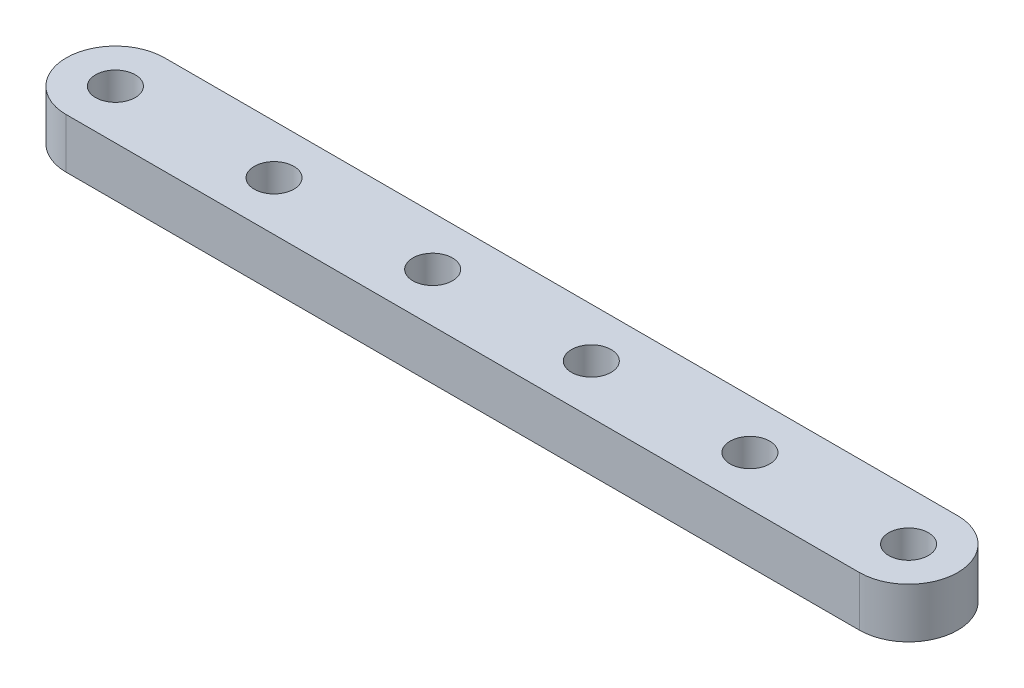
from build123d import *

# Parameters (mm, degrees)
BOSS_EXTRUDE1_DEPTH     = 2
SKETCH2_R               = 1.27
BOSS_EXTRUDE2_DEPTH     = 1.2
CUT_EXTRUDE1_DEPTH      = 35.254233315
CUT_EXTRUDE1_DEPTH_BACK = 35.254233315
SKETCH2_3_R             = 1.27
CUT_EXTRUDE2_DEPTH      = 35.254233315


with BuildPart() as part:
    # Sketch1 → Boss-Extrude1 (new body)
    with BuildSketch(Plane(origin=(0, 0, 0), x_dir=(1, 0, 0), z_dir=(0, 1, 0))):
        with BuildLine():
            Line((24.13, -8.89), (-24.13, -8.89))
            ThreePointArc((-24.13, -8.89), (-33.02, 0), (-24.13, 8.89))
            Line((-24.13, 8.89), (24.13, 8.89))
            ThreePointArc((24.13, 8.89), (33.02, 0), (24.13, -8.89))
        make_face()
    extrude(amount=BOSS_EXTRUDE1_DEPTH)

    # Sketch2 → Boss-Extrude2 (add)
    with BuildSketch(Plane(origin=(0, 2, 0), x_dir=(1, 0, 0), z_dir=(0, 1, 0))):
        with BuildLine():
            ThreePointArc((-25.4, 3.1496), (-28.5496, 0), (-25.4, -3.1496))
            Line((-25.4, -3.1496), (25.4, -3.1496))
            ThreePointArc((25.4, -3.1496), (28.5496, 0), (25.4, 3.1496))
            Line((25.4, 3.1496), (-25.4, 3.1496))
        make_face()
        with Locations((-25.4, 0)):
            Circle(SKETCH2_R, mode=Mode.SUBTRACT)
        with Locations((-15.24, 0)):
            Circle(SKETCH2_R, mode=Mode.SUBTRACT)
        with Locations((-5.08, 0)):
            Circle(SKETCH2_R, mode=Mode.SUBTRACT)
        with Locations((5.08, 0)):
            Circle(SKETCH2_R, mode=Mode.SUBTRACT)
        with Locations((15.24, 0)):
            Circle(SKETCH2_R, mode=Mode.SUBTRACT)
        with Locations((25.4, 0)):
            Circle(SKETCH2_R, mode=Mode.SUBTRACT)
    extrude(amount=BOSS_EXTRUDE2_DEPTH)

    # Sketch2_3 → Cut-Extrude1 (cut, two sides: drawn at the far end of the back side and taken through both)
    with BuildSketch(Plane(origin=(0, 2, 0), x_dir=(1, 0, 0), z_dir=(0, 1, 0)).offset(-CUT_EXTRUDE1_DEPTH_BACK)):
        with Locations((-25.4, 0)):
            Circle(SKETCH2_3_R)
        with Locations((-15.24, 0)):
            Circle(SKETCH2_3_R)
        with Locations((-5.08, 0)):
            Circle(SKETCH2_3_R)
        with Locations((5.08, 0)):
            Circle(SKETCH2_3_R)
        with Locations((15.24, 0)):
            Circle(SKETCH2_3_R)
        with Locations((25.4, 0)):
            Circle(SKETCH2_3_R)
    extrude(amount=CUT_EXTRUDE1_DEPTH + CUT_EXTRUDE1_DEPTH_BACK, mode=Mode.SUBTRACT)

    # Sketch3 → Cut-Extrude2 (cut, through all)
    with BuildSketch(Plane(origin=(0, 2, 0), x_dir=(1, 0, 0), z_dir=(0, 1, 0))):
        with BuildLine():
            Line((24.13, 8.89), (-24.13, 8.89))
            ThreePointArc((-24.13, 8.89), (-33.02, 0), (-24.13, -8.89))
            Line((-24.13, -8.89), (24.13, -8.89))
            ThreePointArc((24.13, -8.89), (33.02, 0), (24.13, 8.89))
        make_face()
        with BuildLine():
            Line((-25.4, -3.1496), (25.4, -3.1496))
            ThreePointArc((25.4, -3.1496), (28.5496, 0), (25.4, 3.1496))
            Line((25.4, 3.1496), (-25.4, 3.1496))
            ThreePointArc((-25.4, 3.1496), (-28.5496, 0), (-25.4, -3.1496))
        make_face(mode=Mode.SUBTRACT)
    extrude(amount=-CUT_EXTRUDE2_DEPTH, mode=Mode.SUBTRACT)


solid = part.part
